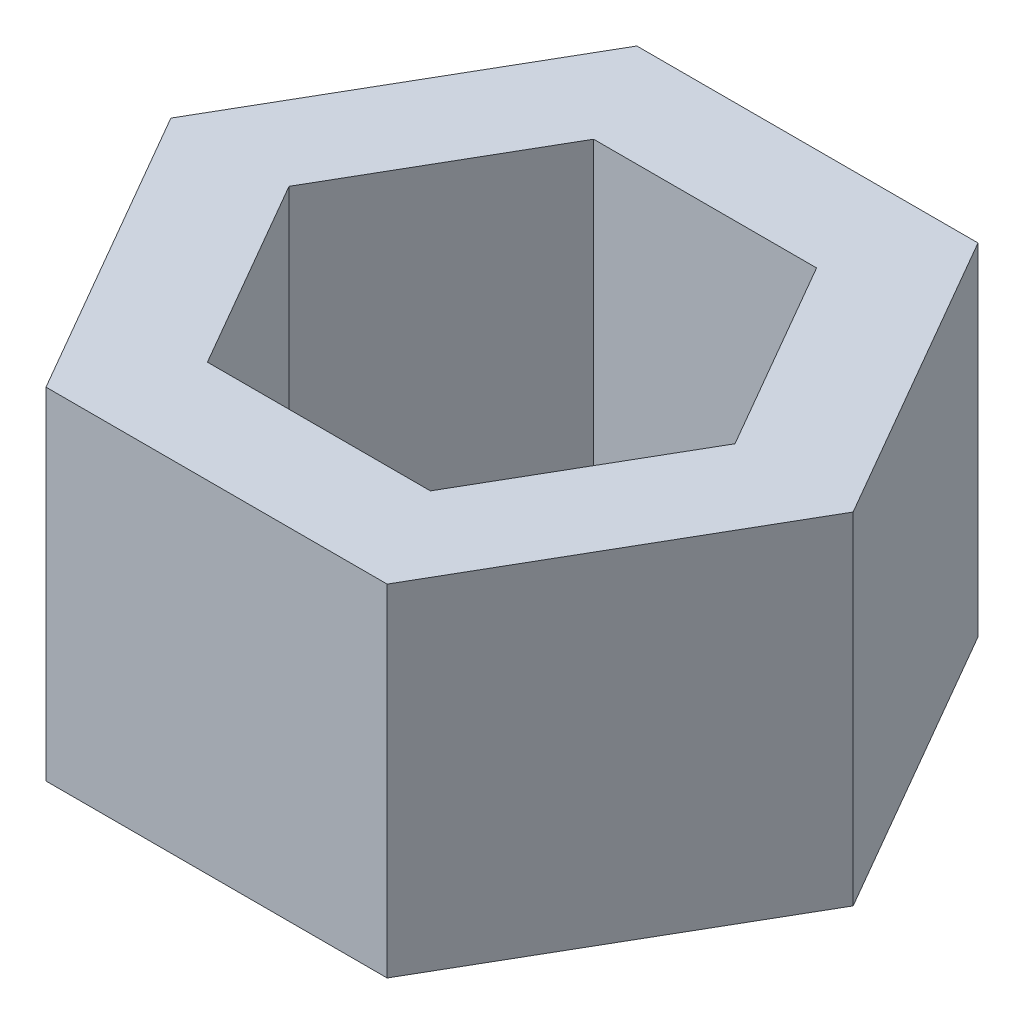
from build123d import *

# Parameters (mm, degrees)
BOSS_EXTRUDE1_DEPTH = 50
CUT_EXTRUDE1_DEPTH  = 51


with BuildPart() as part:
    # Sketch1 → Boss-Extrude1 (new body)
    with BuildSketch(Plane(origin=(0, 0, 0), x_dir=(1, 0, 0), z_dir=(0, 1, 0))):
        Polygon((-25, -43.301270189), (25, -43.301270189), (50, 0), (25, 43.301270189), (-25, 43.301270189), (-50, 0), align=None)
    extrude(amount=BOSS_EXTRUDE1_DEPTH)

    # Sketch2 → Cut-Extrude1 (cut, through all)
    with BuildSketch(Plane(origin=(0, 50, 0), x_dir=(1, 0, 0), z_dir=(0, 1, 0))):
        Polygon((-32.679491924, 0), (-16.339745962, -28.301270189), (16.339745962, -28.301270189), (32.679491924, 0), (16.339745962, 28.301270189), (-16.339745962, 28.301270189), align=None)
    extrude(amount=-CUT_EXTRUDE1_DEPTH, mode=Mode.SUBTRACT)


solid = part.part
